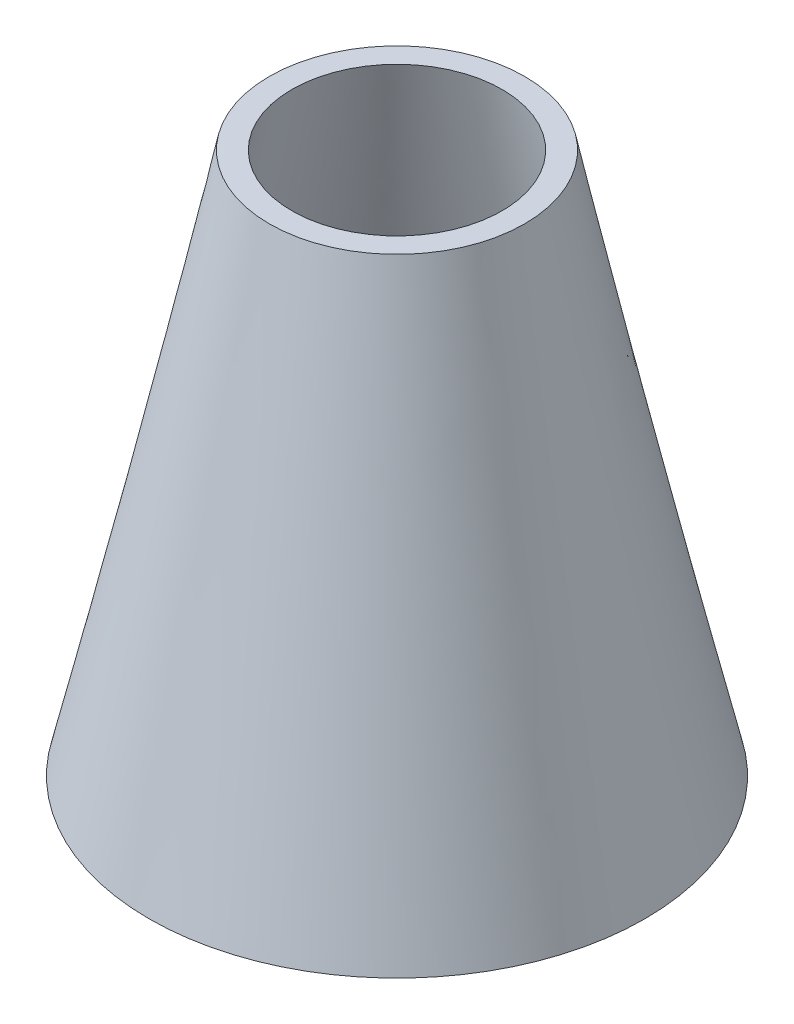
from build123d import *


with BuildPart() as part:
    # Sketch2 → Revolve1 (revolve)
    with BuildSketch(Plane.XY):
        with BuildLine():
            Line((35, 98.40394622), (42.5, 98.40394622))
            add(Edge.make_bspline(
                [(42.5, 98.40394622), (61.409230546, 7.99674), (82.499276575, -81.925467332)],
                knots=[0, 0, 0, 1, 1, 1], degree=2))
            Line((82.499276575, -81.925467332), (74.999276575, -81.925467332))
            add(Edge.make_bspline(
                [(35, 98.40394622), (53.909230546, 7.99674), (74.999276575, -81.925467332)],
                knots=[0, 0, 0, 1, 1, 1], degree=2))
        make_face()
    revolve(axis=Axis((0, 105.448040777, 0), (0, -1, 0)))


solid = part.part
